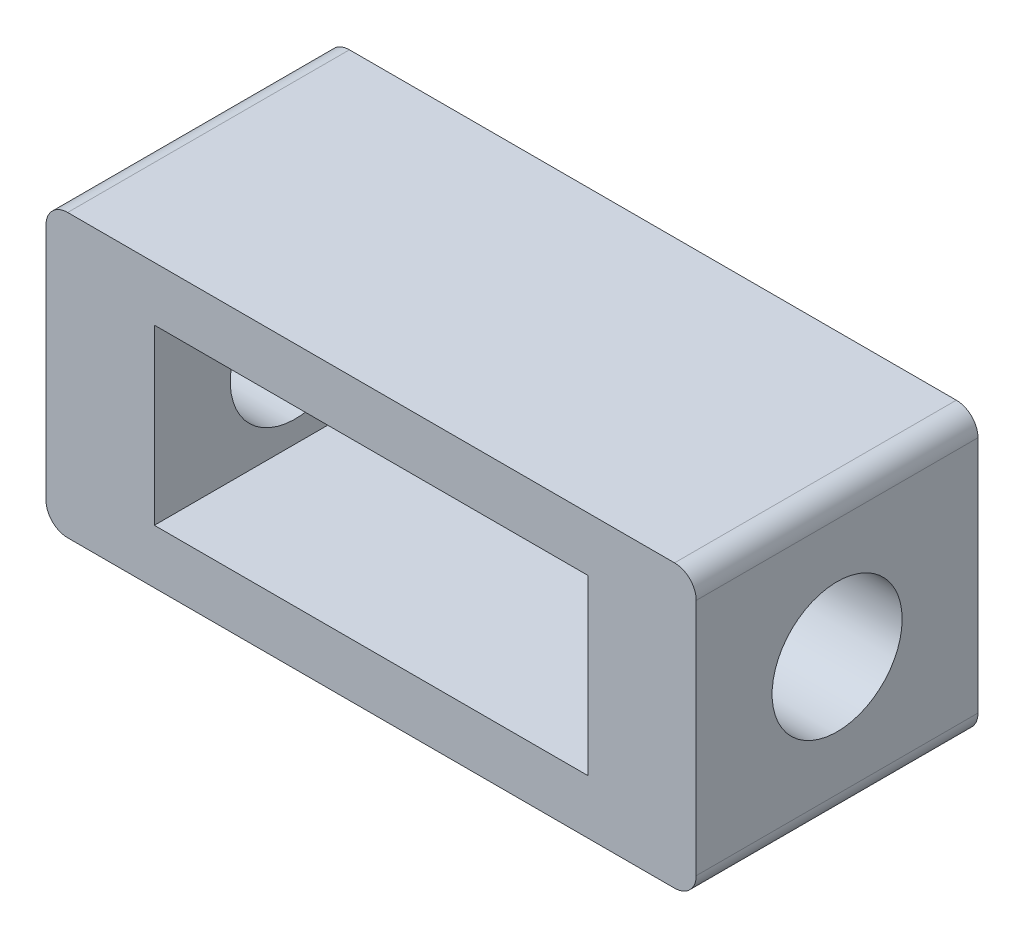
from build123d import *

# Parameters (mm, degrees)
SKETCH1_W           = 40
SKETCH1_H           = 16
BOSS_EXTRUDE1_DEPTH = 26
SKETCH6_R           = 6
CUT_EXTRUDE1_DEPTH  = 61


with BuildPart() as part:
    # Sketch1 → Boss-Extrude1 (new body)
    with BuildSketch(Plane.XY):
        with BuildLine():
            Line((2, 0), (58, 0))
            ThreePointArc((58, 0), (59.414213562, 0.585786438), (60, 2))
            Line((60, 2), (60, 24))
            ThreePointArc((60, 24), (59.414213562, 25.414213562), (58, 26))
            Line((58, 26), (2, 26))
            ThreePointArc((2, 26), (0.585786438, 25.414213562), (0, 24))
            Line((0, 24), (0, 2))
            ThreePointArc((0, 2), (0.585786438, 0.585786438), (2, 0))
        make_face()
        with Locations((30, 13)):
            Rectangle(SKETCH1_W, SKETCH1_H, mode=Mode.SUBTRACT)
    extrude(amount=BOSS_EXTRUDE1_DEPTH)

    # Sketch6 → Cut-Extrude1 (cut, through all)
    with BuildSketch(Plane(origin=(60, 0, 0), x_dir=(0, 0, -1), z_dir=(1, 0, 0))):
        with Locations((-13, 13)):
            Circle(SKETCH6_R)
    extrude(amount=-CUT_EXTRUDE1_DEPTH, mode=Mode.SUBTRACT)


solid = part.part
